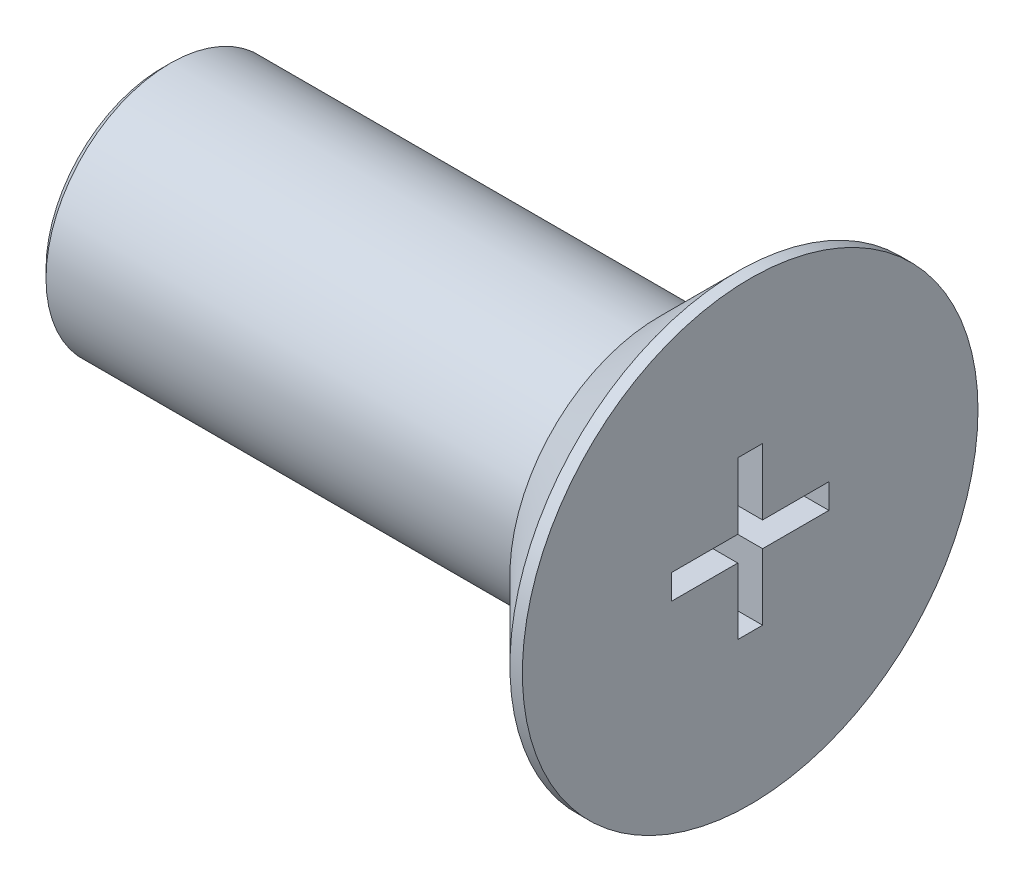
from build123d import *

# Parameters (mm, degrees)
SKETCH_1_R          = 5.5
EXTRUDE_1_DEPTH     = 2.2
SKETCH_2_R          = 3
EXTRUDE_3_DEPTH     = 12
CHAMFER_2_SIZE      = 0.2
CHAMFER_3_SIZE      = 1.9
CUT_EXTRUDE_2_DEPTH = 3


with BuildPart() as part:
    # 草图1 → 凸台-拉伸1 (new body)
    with BuildSketch(Plane(origin=(0, 0, 0), x_dir=(0, 0, -1), z_dir=(1, 0, 0))):
        Circle(SKETCH_1_R)
    extrude(amount=EXTRUDE_1_DEPTH)

    # 草图2 → 凸台-拉伸3 (add)
    with BuildSketch(Plane.ZY):
        Circle(SKETCH_2_R)
    extrude(amount=EXTRUDE_3_DEPTH)

    # 倒角2
    chamfer_2_edges = [part.edges().sort_by_distance(p)[0] for p in [
        (-12, 0, -3),
    ]]
    chamfer(chamfer_2_edges, length=CHAMFER_2_SIZE)

    # 倒角3
    chamfer_3_edges = [part.edges().sort_by_distance(p)[0] for p in [
        (0, 0, 5.5),
    ]]
    chamfer(chamfer_3_edges, length=CHAMFER_3_SIZE)

    # 草图5 → 切除-拉伸2 (cut)
    with BuildSketch(Plane(origin=(2.2, 0, 0), x_dir=(0, 0, -1), z_dir=(1, 0, 0))):
        Polygon((0.3, 0.3), (1.9, 0.3), (1.9, -0.3), (0.3, -0.3), (0.3, -1.9), (-0.3, -1.9), (-0.3, -0.3), (-1.9, -0.3), (-1.9, 0.3), (-0.3, 0.3), (-0.3, 1.9), (0.3, 1.9), align=None)
    extrude(amount=-CUT_EXTRUDE_2_DEPTH, mode=Mode.SUBTRACT)


solid = part.part
